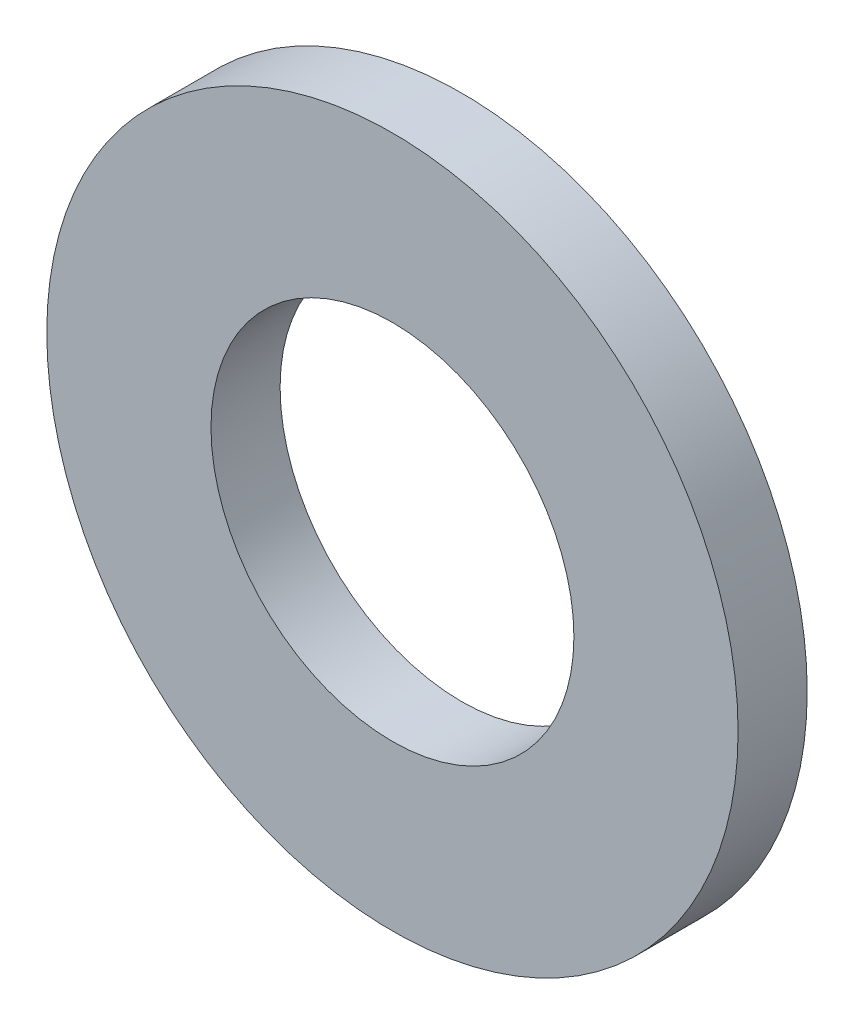
from build123d import *

# Parameters (mm, degrees)
SKETCH1_R           = 10
BOSS_EXTRUDE1_DEPTH = 2
SKETCH2_R           = 5.25
CUT_EXTRUDE2_DEPTH  = 3


with BuildPart() as part:
    # Sketch1 → Boss-Extrude1 (new body)
    with BuildSketch(Plane.XY):
        Circle(SKETCH1_R)
    extrude(amount=BOSS_EXTRUDE1_DEPTH)

    # Sketch2 → Cut-Extrude2 (cut, through all)
    with BuildSketch(Plane.XY):
        Circle(SKETCH2_R)
    extrude(amount=CUT_EXTRUDE2_DEPTH, mode=Mode.SUBTRACT)


solid = part.part
